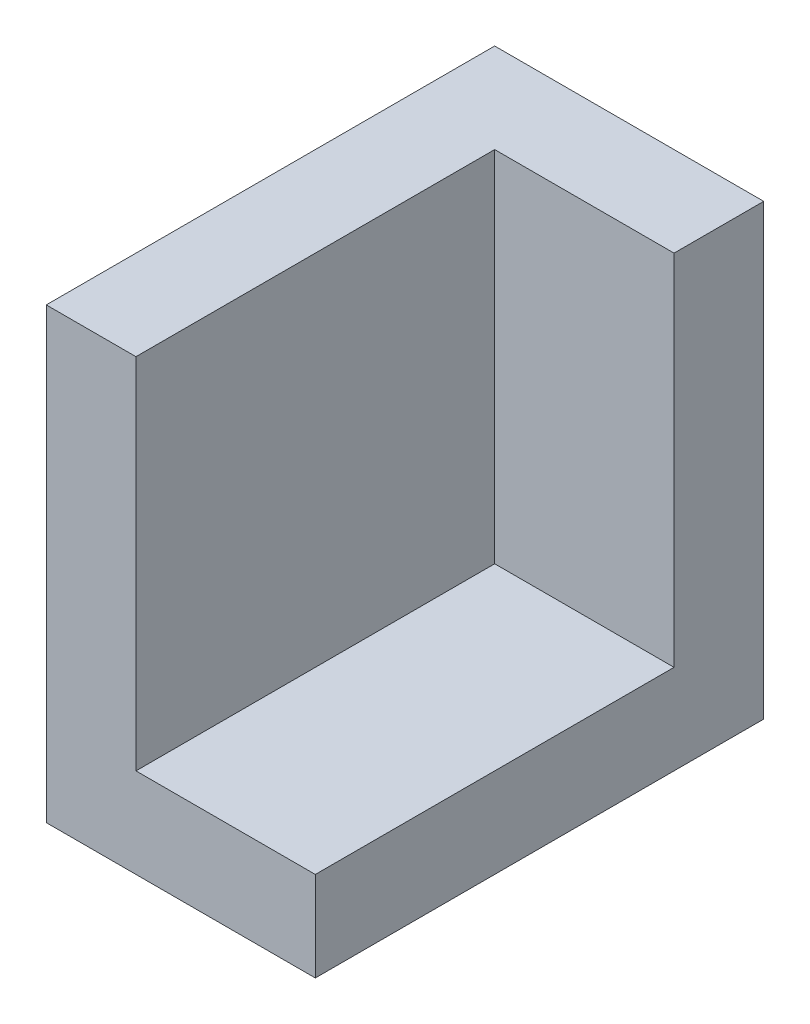
from build123d import *

# Parameters (mm, degrees)
BOSS_EXTRUDE1_DEPTH = 10
SKETCH2_W           = 25
SKETCH2_H           = 25
BOSS_EXTRUDE2_DEPTH = 5


with BuildPart() as part:
    # Sketch1 → Boss-Extrude1 (new body)
    with BuildSketch(Plane(origin=(0, 0, 0), x_dir=(0, 0, -1), z_dir=(1, 0, 0))):
        Polygon((0, 0), (0, 20), (5, 20), (5, -5), (-20, -5), (-20, 0), align=None)
    extrude(amount=BOSS_EXTRUDE1_DEPTH)

    # Sketch2 → Boss-Extrude2 (add)
    with BuildSketch(Plane(origin=(0, 0, 0), x_dir=(0, 0, -1), z_dir=(1, 0, 0))):
        with Locations((-7.5, 7.5)):
            Rectangle(SKETCH2_W, SKETCH2_H)
    extrude(amount=-BOSS_EXTRUDE2_DEPTH)


solid = part.part
